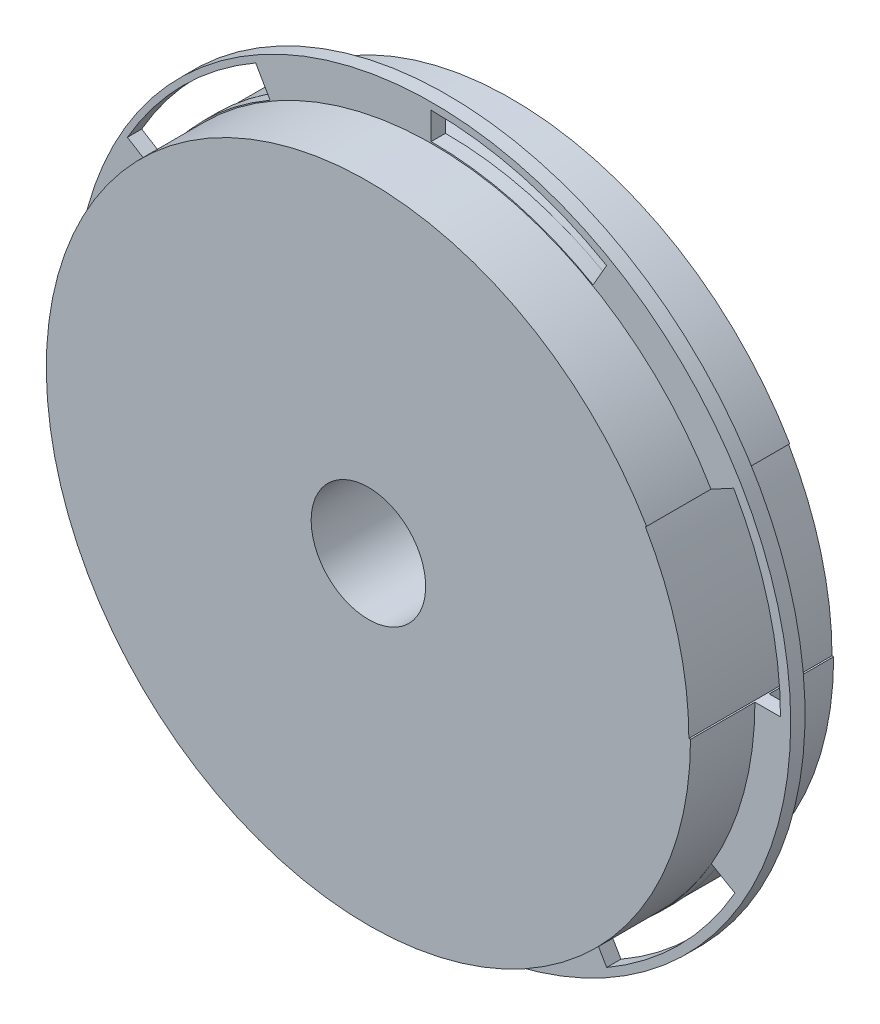
from build123d import *

# Parameters (mm, degrees)
SKETCH1_R           = 25
BOSS_EXTRUDE1_DEPTH = 10
CUT_EXTRUDE5_DEPTH  = 10
SKETCH3_R           = 4
CUT_EXTRUDE6_DEPTH  = 11
SKETCH4_R           = 25
SKETCH4_R_2         = 22.5
CUT_EXTRUDE7_DEPTH  = 4.5
SKETCH5_R           = 25
SKETCH5_R_2         = 22.5
CUT_EXTRUDE8_DEPTH  = 4.5


with BuildPart() as part:
    # Sketch1 → Boss-Extrude1 (new body)
    with BuildSketch(Plane.XY):
        with Locations((-23.589512773, 15.601245947)):
            Circle(SKETCH1_R)
    extrude(amount=BOSS_EXTRUDE1_DEPTH)

    # Sketch2 → Cut-Extrude5 (cut)
    with BuildSketch(Plane.XY.offset(10)):
        with BuildLine():
            ThreePointArc((-12.397365997, 35.187022257), (-17.85188328, 37.442250567), (-23.705219222, 38.201376294))
            Line((-23.705219222, 38.201376294), (-23.705219222, 40.101382086))
            ThreePointArc((-23.705219222, 40.101382086), (-17.360126716, 39.277511034), (-11.447365997, 36.832470524))
            Line((-11.447365997, 36.832470524), (-12.397365997, 35.187022257))
        make_face()
        with BuildLine():
            ThreePointArc((-46.199031525, 15.594523409), (-45.424857891, 9.743158722), (-43.155612085, 4.294458236))
            Line((-43.155612085, 4.294458236), (-44.922959514, 3.351177878))
            ThreePointArc((-44.922959514, 3.351177878), (-47.382012507, 9.258124703), (-48.220925671, 15.601245947))
            Line((-48.220925671, 15.601245947), (-46.199031525, 15.594523409))
        make_face()
        with BuildLine():
            ThreePointArc((-34.956202123, 35.082783969), (-39.636545772, 31.486647592), (-43.220635908, 26.797072833))
            Line((-43.220635908, 26.797072833), (-44.922959514, 27.851314017))
            ThreePointArc((-44.922959514, 27.851314017), (-41.036920001, 32.93438979), (-35.963072446, 36.832470524))
            Line((-35.963072446, 36.832470524), (-34.956202123, 35.082783969))
        make_face()
        with BuildLine():
            ThreePointArc((0.695590424, 15.601236334), (-0.136388558, 21.916313805), (-2.574473081, 27.800881448))
            Line((-2.574473081, 27.800881448), (-4.247828914, 26.899070207))
            ThreePointArc((-4.247828914, 26.899070207), (-1.978583107, 21.450369721), (-1.204409474, 15.599005033))
            Line((-1.204409474, 15.599005033), (0.695590424, 15.601236334))
        make_face()
        with BuildLine():
            ThreePointArc((-12.397365997, -3.984530362), (-7.717022348, -0.388393985), (-4.132932213, 4.301180774))
            Line((-4.132932213, 4.301180774), (-2.48747893, 3.351177878))
            ThreePointArc((-2.48747893, 3.351177878), (-6.373518443, -1.731897895), (-11.447365997, -5.629978629))
            Line((-11.447365997, -5.629978629), (-12.397365997, -3.984530362))
        make_face()
        with BuildLine():
            ThreePointArc((-35.013072446, -3.984530362), (-29.558555164, -6.239758672), (-23.705219222, -6.998884399))
            Line((-23.705219222, -6.998884399), (-23.705219222, -8.898890191))
            ThreePointArc((-23.705219222, -8.898890191), (-30.050311728, -8.075019139), (-35.963072446, -5.629978629))
            Line((-35.963072446, -5.629978629), (-35.013072446, -3.984530362))
        make_face()
    extrude(amount=-CUT_EXTRUDE5_DEPTH, mode=Mode.SUBTRACT)

    # Sketch3 → Cut-Extrude6 (cut, through all)
    with BuildSketch(Plane(origin=(0, 0, 0), x_dir=(-1, 0, 0), z_dir=(0, 0, -1))):
        with Locations((23.589512773, 15.601245947)):
            Circle(SKETCH3_R)
    extrude(amount=-CUT_EXTRUDE6_DEPTH, mode=Mode.SUBTRACT)

    # Sketch4 → Cut-Extrude7 (cut)
    with BuildSketch(Plane.XY.offset(10)):
        with Locations((-23.589512773, 15.601245947)):
            Circle(SKETCH4_R)
        with Locations((-23.589512773, 15.601245947)):
            Circle(SKETCH4_R_2, mode=Mode.SUBTRACT)
    extrude(amount=-CUT_EXTRUDE7_DEPTH, mode=Mode.SUBTRACT)

    # Sketch5 → Cut-Extrude8 (cut)
    with BuildSketch(Plane(origin=(0, 0, 0), x_dir=(-1, 0, 0), z_dir=(0, 0, -1))):
        with Locations((23.589512773, 15.601245947)):
            Circle(SKETCH5_R)
        with Locations((23.589512773, 15.601245947)):
            Circle(SKETCH5_R_2, mode=Mode.SUBTRACT)
    extrude(amount=-CUT_EXTRUDE8_DEPTH, mode=Mode.SUBTRACT)


solid = part.part
